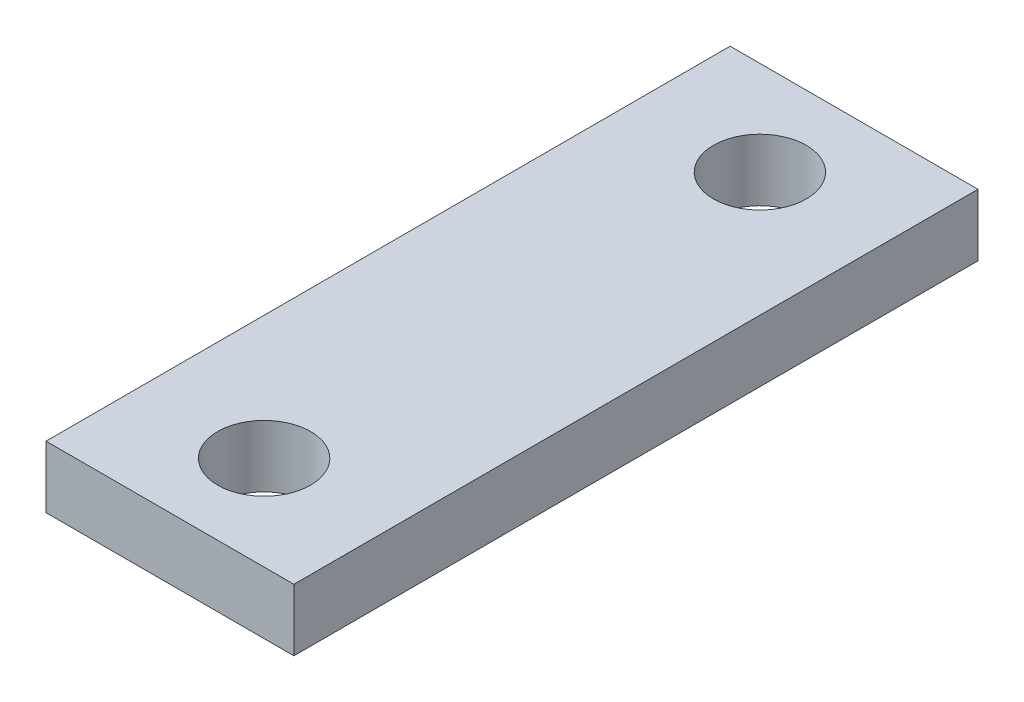
from build123d import *

# Parameters (mm, degrees)
SKETCH2_W           = 25.4
SKETCH2_H           = 70.104
SKETCH2_R           = 4.7625
BOSS_EXTRUDE1_DEPTH = 6.35


with BuildPart() as part:
    # Sketch2 → Boss-Extrude1 (new body)
    with BuildSketch(Plane(origin=(0, 0, 0), x_dir=(1, 0, 0), z_dir=(0, 1, 0))):
        Rectangle(SKETCH2_W, SKETCH2_H)
        with Locations((0, 25.4)):
            Circle(SKETCH2_R, mode=Mode.SUBTRACT)
        with Locations((0, -25.4)):
            Circle(SKETCH2_R, mode=Mode.SUBTRACT)
    extrude(amount=BOSS_EXTRUDE1_DEPTH)


solid = part.part
